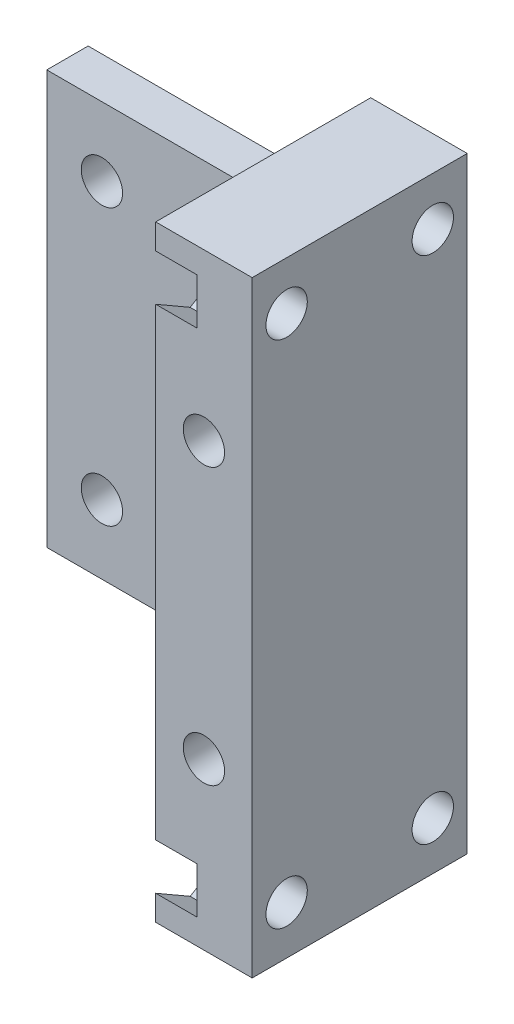
from build123d import *

# Parameters (mm, degrees)
SKETCH1_W           = 27.5
SKETCH1_H           = 30
SKETCH1_R           = 1.500000001
SKETCH1_R_2         = 1.5
BOSS_EXTRUDE1_DEPTH = 5
SKETCH1_3_W         = 7
SKETCH1_3_H         = 30
SKETCH1_3_R         = 1.500000001
SKETCH1_3_R_2       = 1.5
BOSS_EXTRUDE2_DEPTH = 15.6
SKETCH4_R           = 1.5
BOSS_EXTRUDE3_DEPTH = 4
BOSS_EXTRUDE4_START = -4
BOSS_EXTRUDE4_DEPTH = 3
SKETCH5_W           = 20.5
SKETCH5_H           = 30
CUT_EXTRUDE1_DEPTH  = 2


with BuildPart() as part:
    # Sketch1 → Boss-Extrude1 (new body)
    with BuildSketch(Plane.XY):
        with Locations((359.752910404, -328.295226576)):
            Rectangle(SKETCH1_W, SKETCH1_H)
        with Locations((370.002910404, -338.295226576)):
            Circle(SKETCH1_R, mode=Mode.SUBTRACT)
        with Locations((370.002910404, -318.295226576)):
            Circle(SKETCH1_R_2, mode=Mode.SUBTRACT)
        with Locations((350.002910404, -318.295226576)):
            Circle(SKETCH1_R_2, mode=Mode.SUBTRACT)
        with Locations((350.002910404, -338.295226576)):
            Circle(SKETCH1_R_2, mode=Mode.SUBTRACT)
    extrude(amount=BOSS_EXTRUDE1_DEPTH)

    # Sketch1_3 → Boss-Extrude2 (add)
    with BuildSketch(Plane.XY):
        with Locations((370.002910404, -328.295226576)):
            Rectangle(SKETCH1_3_W, SKETCH1_3_H)
        with Locations((370.002910404, -338.295226576)):
            Circle(SKETCH1_3_R, mode=Mode.SUBTRACT)
        with Locations((370.002910404, -318.295226576)):
            Circle(SKETCH1_3_R_2, mode=Mode.SUBTRACT)
    extrude(amount=BOSS_EXTRUDE2_DEPTH)

    # Sketch4 → Boss-Extrude3 (add)
    with BuildSketch(Plane(origin=(373.502910404, 0, 0), x_dir=(0, 0, -1), z_dir=(1, 0, 0))):
        Polygon((-15.6, -311.469542357), (-15.6, -313.295226576), (0, -313.295226576), (0, -311.469542357), (-2.5, -312.91291803), (-5.2, -311.354072303), (-5.2, -308.236380849), (-2.5, -306.677535123), (0, -308.120910796), (0, -306.295226576), (-15.6, -306.295226576), (-15.6, -308.120910796), (-13.1, -306.677535123), (-10.4, -308.236380849), (-10.4, -311.354072303), (-13.1, -312.91291803), align=None)
        Polygon((-2.5, -312.91291803), (0, -311.469542357), (0, -308.120910796), (-2.5, -306.677535123), (-5.2, -308.236380849), (-5.2, -311.354072303), align=None)
        with Locations((-2.5, -309.795226576)):
            Circle(SKETCH4_R, mode=Mode.SUBTRACT)
        Polygon((-15.6, -308.120910796), (-15.6, -311.469542357), (-13.1, -312.91291803), (-10.4, -311.354072303), (-10.4, -308.236380849), (-13.1, -306.677535123), align=None)
        with Locations((-13.1, -309.795226576)):
            Circle(SKETCH4_R, mode=Mode.SUBTRACT)
    boss_extrude3 = extrude(amount=-BOSS_EXTRUDE3_DEPTH)

    # Sketch4_3 → Boss-Extrude4 (add)
    with BuildSketch(Plane(origin=(373.502910404, 0, 0), x_dir=(0, 0, -1), z_dir=(1, 0, 0)).offset(BOSS_EXTRUDE4_START)):
        Polygon((-15.6, -311.469542357), (-15.6, -313.295226576), (0, -313.295226576), (0, -311.469542357), (-2.5, -312.91291803), (-5.2, -311.354072303), (-5.2, -308.236380849), (-2.5, -306.677535123), (0, -308.120910796), (0, -306.295226576), (-15.6, -306.295226576), (-15.6, -308.120910796), (-13.1, -306.677535123), (-10.4, -308.236380849), (-10.4, -311.354072303), (-13.1, -312.91291803), align=None)
    boss_extrude4 = extrude(amount=-BOSS_EXTRUDE4_DEPTH)

    # Mirror1: Boss-Extrude3, Boss-Extrude4 across plane
    add(boss_extrude3.mirror(Plane.ZX.offset(-328.295226576)))
    add(boss_extrude4.mirror(Plane.ZX.offset(-328.295226576)))

    # Sketch5 → Cut-Extrude1 (cut)
    with BuildSketch(Plane.XY.offset(5)):
        with Locations((356.252910404, -328.295226576)):
            Rectangle(SKETCH5_W, SKETCH5_H)
    extrude(amount=-CUT_EXTRUDE1_DEPTH, mode=Mode.SUBTRACT)


solid = part.part
